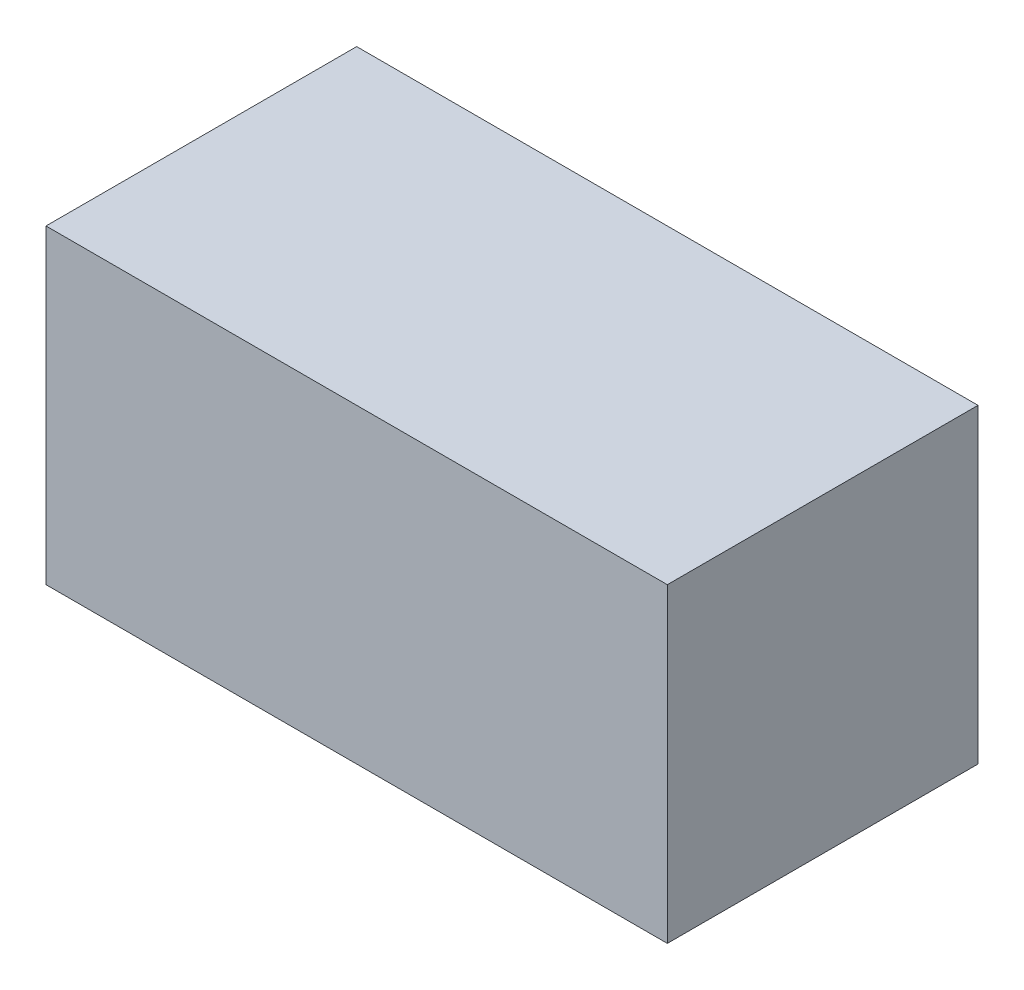
from build123d import *

# Parameters (mm, degrees)
SKETCH1_W         = 40
SKETCH1_H         = 20
HEATER_BODY_DEPTH = 20


with BuildPart() as part:
    # Sketch1 → Heater Body (new body)
    with BuildSketch(Plane(origin=(0, 0, 0), x_dir=(1, 0, 0), z_dir=(0, 1, 0))):
        Rectangle(SKETCH1_W, SKETCH1_H)
    extrude(amount=HEATER_BODY_DEPTH)


solid = part.part
